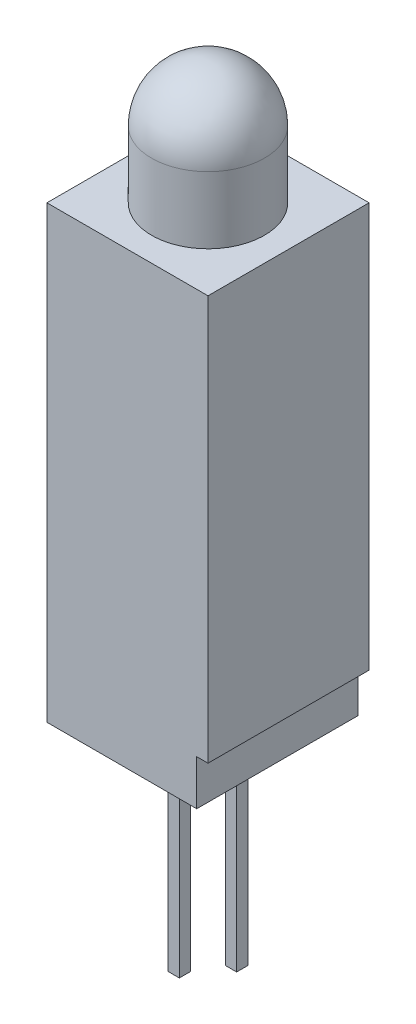
from build123d import *

# Parameters (mm, degrees)
EXTRUDE1_DEPTH     = 3.57
SKETCH1_5_W        = 0.5
SKETCH1_5_H        = 10.2
SKETCH1_5_H_2      = 8.7
EXTRUDE2_DEPTH     = 0.25
SKETCH2_W          = 0.025316456
SKETCH2_H          = 0.026582278
CUT_EXTRUDE1_DEPTH = 0.01


with BuildPart() as part:
    # Sketch1 → Extrude1 (new body, symmetric)
    with BuildSketch(Plane.XY):
        Polygon((0, 0), (-3.57, 0), (-3.57, -19.94), (-1.52, -19.94), (-1.02, -19.94), (1.02, -19.94), (1.52, -19.94), (3.07, -19.94), (3.07, -17.94), (3.57, -17.94), (3.57, 0), (2.5, 0), align=None)
    extrude(amount=EXTRUDE1_DEPTH, both=True)

    # Sketch1_4 → Revolve1 (revolve)
    with BuildSketch(Plane.XY, mode=Mode.PRIVATE) as revolve1_sk:
        with BuildLine():
            Line((0, 5.46), (0, 0))
            Line((0, 0), (2.5, 0))
            Line((2.5, 0), (2.5, 2.96))
            ThreePointArc((2.5, 2.96), (1.767766953, 4.727766953), (0, 5.46))
        make_face()
    revolve(revolve1_sk.sketch.rotate(Axis((0, 0, 0), (0, 1, 0)), 180), axis=Axis((0, 0, 0), (0, 1, 0)))  # turned: the seam where the file's is

    # Sketch1_5 → Extrude2 (add, symmetric)
    with BuildSketch(Plane.XY):
        with Locations((-1.27, -25.04)):
            Rectangle(SKETCH1_5_W, SKETCH1_5_H)
        with Locations((1.27, -24.29)):
            Rectangle(SKETCH1_5_W, SKETCH1_5_H_2)
    extrude(amount=EXTRUDE2_DEPTH, both=True)

    # Sketch2 → Cut-Extrude1 (cut)
    with BuildSketch(Plane.XZ.offset(19.94)):
        Polygon((-0.822151899, -2.5058483), (-0.845609177, -2.580531844), (-0.870352057, -2.580531844), (-0.886768196, -2.53019561), (-0.902294304, -2.580531844), (-0.928026108, -2.580531844), (-0.951265823, -2.5058483), (-0.926087816, -2.5058483), (-0.913093354, -2.557331686), (-0.896677215, -2.5058483), (-0.875178006, -2.5058483), (-0.858860759, -2.557331686), (-0.846044304, -2.5058483), align=None)
        Polygon((-0.687974684, -2.5058483), (-0.711431962, -2.580531844), (-0.736174842, -2.580531844), (-0.752590981, -2.53019561), (-0.768117089, -2.580531844), (-0.793848892, -2.580531844), (-0.817088608, -2.5058483), (-0.791910601, -2.5058483), (-0.778916139, -2.557331686), (-0.7625, -2.5058483), (-0.741000791, -2.5058483), (-0.724683544, -2.557331686), (-0.711867089, -2.5058483), align=None)
        Polygon((-0.553797468, -2.5058483), (-0.577254747, -2.580531844), (-0.601997627, -2.580531844), (-0.618413766, -2.53019561), (-0.633939873, -2.580531844), (-0.659671677, -2.580531844), (-0.682911392, -2.5058483), (-0.657733386, -2.5058483), (-0.644738924, -2.557331686), (-0.628322785, -2.5058483), (-0.606823576, -2.5058483), (-0.590506329, -2.557331686), (-0.577689873, -2.5058483), align=None)
        with Locations((-0.525949367, -2.567240705)):
            Rectangle(SKETCH2_W, SKETCH2_H)
        with BuildLine():
            add(Edge.make_bspline(
                [(-0.409493671, -2.549360958), (-0.40953016, -2.5505831), (-0.409601812, -2.552982978), (-0.41021153, -2.556490556), (-0.411205016, -2.559815261), (-0.412579134, -2.562977922), (-0.414367936, -2.56595654), (-0.416577526, -2.568736817), (-0.419141939, -2.571371618), (-0.422108149, -2.573777748), (-0.425388259, -2.575982124), (-0.428985835, -2.577879123), (-0.432864539, -2.579475606), (-0.437013125, -2.580814158), (-0.441459564, -2.581802738), (-0.446177094, -2.582526684), (-0.451170512, -2.583000013), (-0.45459409, -2.58304198), (-0.456348892, -2.58306349)],
                knots=[0, 0, 0, 0, 0.907352243, 1.781736951, 2.63548328, 3.47985091, 4.336556021, 5.208523475, 6.112432747, 7.062451073, 8.040435374, 9.043840564, 10.077958095, 11.152835584, 12.277940427, 13.457536469, 14.696825396, 16, 16, 16, 16], degree=3))
            add(Edge.make_bspline(
                [(-0.456348892, -2.58306349), (-0.458367148, -2.583039418), (-0.46227633, -2.582992794), (-0.467939855, -2.582564195), (-0.473207892, -2.581918055), (-0.478103607, -2.580951513), (-0.482708206, -2.579750748), (-0.487141474, -2.578459457), (-0.491422786, -2.576995041), (-0.494195876, -2.575894883), (-0.49556962, -2.575349882)],
                knots=[0, 0, 0, 0, 1.203215828, 2.33052265, 3.384689099, 4.366106119, 5.303329643, 6.221311756, 7.118865988, 8, 8, 8, 8], degree=3))
            Line((-0.49556962, -2.575349882), (-0.49556962, -2.55141792))
            Line((-0.49556962, -2.55141792), (-0.492721519, -2.55141792))
            add(Edge.make_bspline(
                [(-0.492721519, -2.55141792), (-0.491356205, -2.552499375), (-0.488633592, -2.554655936), (-0.484200359, -2.557418541), (-0.479552713, -2.559820704), (-0.474707243, -2.561794706), (-0.469810398, -2.56338103), (-0.46493502, -2.564474558), (-0.460169433, -2.565221907), (-0.457010864, -2.565302413), (-0.455458861, -2.565341971)],
                knots=[0, 0, 0, 0, 1.030622468, 2.055194264, 3.087043286, 4.125157485, 5.149848264, 6.130935704, 7.081611712, 8, 8, 8, 8], degree=3))
            add(Edge.make_bspline(
                [(-0.455458861, -2.565341971), (-0.455030085, -2.565341048), (-0.454112108, -2.56533907), (-0.452650581, -2.565211343), (-0.45099877, -2.565115766), (-0.449226261, -2.564908582), (-0.447429535, -2.564686722), (-0.445767134, -2.564311796), (-0.444257539, -2.563946929), (-0.443351018, -2.563578932), (-0.442919304, -2.56340368)],
                knots=[0, 0, 0, 0, 0.806402781, 1.726445712, 2.758724871, 3.919014682, 5.083870887, 6.16165551, 7.124521387, 8, 8, 8, 8], degree=3))
            add(Edge.make_bspline(
                [(-0.442919304, -2.56340368), (-0.442439741, -2.563175538), (-0.441497298, -2.562727191), (-0.440203698, -2.561916872), (-0.439036018, -2.561033407), (-0.437978647, -2.560068477), (-0.437104366, -2.558902726), (-0.436480499, -2.557494054), (-0.436135606, -2.555845036), (-0.436096583, -2.554669833), (-0.436075949, -2.554048458)],
                knots=[0, 0, 0, 0, 1.024747072, 2.013846092, 2.940605744, 3.850156746, 4.769278501, 5.73222711, 6.800942666, 8, 8, 8, 8], degree=3))
            add(Edge.make_bspline(
                [(-0.436075949, -2.554048458), (-0.436107794, -2.553502821), (-0.43617041, -2.552429937), (-0.436747603, -2.550894823), (-0.437657041, -2.549485655), (-0.438938631, -2.54821688), (-0.440531807, -2.547067346), (-0.442474191, -2.546085041), (-0.444724312, -2.545211853), (-0.446368382, -2.544793876), (-0.447231013, -2.544574566)],
                knots=[0, 0, 0, 0, 0.82557554, 1.623324704, 2.456147571, 3.35491006, 4.343819762, 5.427079081, 6.650009487, 8, 8, 8, 8], degree=3))
            add(Edge.make_bspline(
                [(-0.447231013, -2.544574566), (-0.449199639, -2.544126326), (-0.453238649, -2.543206675), (-0.459388473, -2.542067921), (-0.465516824, -2.540793061), (-0.469469591, -2.539586418), (-0.471400316, -2.538997034)],
                knots=[0, 0, 0, 0, 0.976100998, 2.002656142, 3.024398856, 4, 4, 4, 4], degree=3))
            add(Edge.make_bspline(
                [(-0.471400316, -2.538997034), (-0.472438835, -2.538644044), (-0.474460408, -2.537956916), (-0.477351919, -2.536795256), (-0.480013147, -2.535525427), (-0.48245286, -2.534169872), (-0.484653549, -2.532697332), (-0.486647817, -2.531155954), (-0.488410933, -2.529515914), (-0.489957738, -2.527776148), (-0.491282641, -2.525925445), (-0.492435025, -2.523980248), (-0.493417646, -2.521924828), (-0.494195684, -2.519754605), (-0.494820323, -2.51748095), (-0.495239305, -2.515103238), (-0.495538322, -2.512620109), (-0.495559046, -2.510925724), (-0.49556962, -2.510061117)],
                knots=[0, 0, 0, 0, 1.287047841, 2.5053592, 3.654260482, 4.74538952, 5.777514103, 6.75871007, 7.700244599, 8.599107454, 9.48590269, 10.366941872, 11.24940663, 12.154970331, 13.068988358, 14.012872203, 14.986013017, 16, 16, 16, 16], degree=3))
            add(Edge.make_bspline(
                [(-0.49556962, -2.510061117), (-0.495532318, -2.508904972), (-0.495458909, -2.5066297), (-0.49485748, -2.503300655), (-0.49383089, -2.500151919), (-0.492444827, -2.497148456), (-0.490616199, -2.49433537), (-0.488431404, -2.491656822), (-0.485807357, -2.489185231), (-0.482830235, -2.486884897), (-0.479542851, -2.484805499), (-0.476003867, -2.482974942), (-0.472234578, -2.481438291), (-0.468249032, -2.480164397), (-0.464030563, -2.479209726), (-0.45959333, -2.478490794), (-0.454919541, -2.478077612), (-0.45172812, -2.478026362), (-0.450098892, -2.478000199)],
                knots=[0, 0, 0, 0, 0.894990994, 1.761326291, 2.609044902, 3.454222546, 4.315366365, 5.200560057, 6.125081389, 7.100429509, 8.110379559, 9.133447974, 10.182136699, 11.259192205, 12.370181258, 13.528580438, 14.738335141, 16, 16, 16, 16], degree=3))
            add(Edge.make_bspline(
                [(-0.450098892, -2.478000199), (-0.448430198, -2.478022352), (-0.44509564, -2.47806662), (-0.4401143, -2.478445177), (-0.435159872, -2.478997489), (-0.430297448, -2.479846729), (-0.425605285, -2.480814961), (-0.42118617, -2.481914234), (-0.417106618, -2.48315174), (-0.414532965, -2.484106142), (-0.413291139, -2.484566655)],
                knots=[0, 0, 0, 0, 1.065407564, 2.129008667, 3.188544425, 4.247469455, 5.279542408, 6.247502114, 7.154394069, 8, 8, 8, 8], degree=3))
            Line((-0.413291139, -2.484566655), (-0.413291139, -2.507114123))
            Line((-0.413291139, -2.507114123), (-0.416119462, -2.507114123))
            add(Edge.make_bspline(
                [(-0.416119462, -2.507114123), (-0.417192966, -2.506314835), (-0.419383743, -2.50468367), (-0.423033347, -2.502581934), (-0.427000967, -2.500641843), (-0.431282594, -2.498950186), (-0.435742374, -2.497492179), (-0.440325133, -2.496472621), (-0.444951348, -2.495830913), (-0.448053052, -2.495758125), (-0.44960443, -2.495721718)],
                knots=[0, 0, 0, 0, 0.892265782, 1.820912499, 2.804518821, 3.836954028, 4.889985052, 5.931488012, 6.965393252, 8, 8, 8, 8], degree=3))
            add(Edge.make_bspline(
                [(-0.44960443, -2.495721718), (-0.450700035, -2.49574362), (-0.452897679, -2.495787554), (-0.45616687, -2.49617244), (-0.459407348, -2.496811293), (-0.46144203, -2.497627345), (-0.462460443, -2.4980358)],
                knots=[0, 0, 0, 0, 0.999122297, 2.004111588, 3.001004448, 4, 4, 4, 4], degree=3))
            add(Edge.make_bspline(
                [(-0.462460443, -2.4980358), (-0.462894173, -2.498236979), (-0.463761342, -2.498639203), (-0.464968884, -2.499418828), (-0.466089856, -2.500335172), (-0.467085439, -2.501387929), (-0.467929873, -2.502556283), (-0.468548899, -2.503823865), (-0.468923392, -2.505187747), (-0.468965739, -2.506122846), (-0.468987342, -2.506599882)],
                knots=[0, 0, 0, 0, 1.004925302, 2.009180302, 3.014392739, 4.04465309, 5.049195417, 6.035570224, 6.99785458, 8, 8, 8, 8], degree=3))
            add(Edge.make_bspline(
                [(-0.468987342, -2.506599882), (-0.468952904, -2.507238048), (-0.468887095, -2.508457523), (-0.468280511, -2.510173319), (-0.467295678, -2.511651753), (-0.466135073, -2.512646673), (-0.465017943, -2.513344111), (-0.463982284, -2.513854622), (-0.462773057, -2.514337981), (-0.461401809, -2.514835449), (-0.459865482, -2.515326637), (-0.458156925, -2.515802183), (-0.456274208, -2.516251479), (-0.454958333, -2.51653767), (-0.454272152, -2.516686908)],
                knots=[0, 0, 0, 0, 1.173816843, 2.243057204, 3.312297565, 4.415174738, 5.03266065, 5.73970059, 6.541434878, 7.433956553, 8.430083051, 9.515931566, 10.70464786, 12, 12, 12, 12], degree=3))
            add(Edge.make_bspline(
                [(-0.454272152, -2.516686908), (-0.452439229, -2.517062352), (-0.448844263, -2.517798723), (-0.443445039, -2.518911089), (-0.437940051, -2.520176448), (-0.434268899, -2.521328444), (-0.432357595, -2.521928205)],
                knots=[0, 0, 0, 0, 0.995749986, 1.952994291, 2.934271555, 4, 4, 4, 4], degree=3))
            add(Edge.make_bspline(
                [(-0.432357595, -2.521928205), (-0.431411107, -2.522247564), (-0.429559623, -2.522872282), (-0.426918075, -2.523956966), (-0.424469022, -2.525139055), (-0.422190751, -2.526361541), (-0.42012867, -2.527724758), (-0.418235447, -2.529139405), (-0.416552428, -2.530667514), (-0.415054478, -2.532280372), (-0.413736077, -2.533990804), (-0.412601114, -2.535828907), (-0.411637968, -2.537783436), (-0.410829836, -2.539856508), (-0.41025182, -2.542063576), (-0.409817762, -2.544389876), (-0.40952694, -2.546835192), (-0.409504884, -2.548509638), (-0.409493671, -2.549360958)],
                knots=[0, 0, 0, 0, 1.237386967, 2.420528625, 3.534815053, 4.605870898, 5.620827102, 6.594482803, 7.531295079, 8.432978826, 9.318460435, 10.202471551, 11.10474705, 12.014900263, 12.954095338, 13.926516828, 14.945802342, 16, 16, 16, 16], degree=3))
        make_face()
        with BuildLine():
            Line((-0.317088608, -2.580531844), (-0.341139241, -2.580531844))
            Line((-0.341139241, -2.580531844), (-0.341139241, -2.572699566))
            add(Edge.make_bspline(
                [(-0.341139241, -2.572699566), (-0.342232496, -2.573508233), (-0.344340276, -2.575067332), (-0.347514015, -2.577146096), (-0.350542736, -2.578929258), (-0.353464337, -2.580471411), (-0.356479693, -2.581662258), (-0.359707195, -2.582484114), (-0.363209459, -2.582985234), (-0.365636434, -2.583036825), (-0.366890823, -2.58306349)],
                knots=[0, 0, 0, 0, 1.150906677, 2.218931226, 3.20955724, 4.125565256, 5.012676028, 5.946647191, 6.938718366, 8, 8, 8, 8], degree=3))
            add(Edge.make_bspline(
                [(-0.366890823, -2.58306349), (-0.367907168, -2.583040761), (-0.369886286, -2.582996501), (-0.372763616, -2.582651763), (-0.375470927, -2.582113617), (-0.377987077, -2.581307761), (-0.380352422, -2.580333644), (-0.382503941, -2.579074557), (-0.38449163, -2.57761522), (-0.386295007, -2.575938284), (-0.387885627, -2.574017322), (-0.389272677, -2.571894572), (-0.390448489, -2.569559933), (-0.391390127, -2.567008566), (-0.392145061, -2.564250122), (-0.392669038, -2.561270915), (-0.392989618, -2.558083776), (-0.393021559, -2.555888647), (-0.393037975, -2.554760484)],
                knots=[0, 0, 0, 0, 1.108935798, 2.159418225, 3.158520219, 4.116592843, 5.038730546, 5.944611115, 6.829677354, 7.725673622, 8.624842385, 9.544872214, 10.487719724, 11.471363217, 12.50822837, 13.604887271, 14.769056852, 16, 16, 16, 16], degree=3))
            Line((-0.393037975, -2.554760484), (-0.393037975, -2.5058483))
            Line((-0.393037975, -2.5058483), (-0.368987342, -2.5058483))
            Line((-0.368987342, -2.5058483), (-0.368987342, -2.543427414))
            add(Edge.make_bspline(
                [(-0.368987342, -2.543427414), (-0.368985706, -2.544343885), (-0.368982576, -2.546098101), (-0.368900237, -2.548603907), (-0.368779336, -2.55087208), (-0.368640631, -2.552914108), (-0.368387615, -2.554760859), (-0.368009906, -2.55642702), (-0.36753908, -2.557946622), (-0.367074761, -2.558853324), (-0.366851266, -2.559289756)],
                knots=[0, 0, 0, 0, 1.361401701, 2.605856924, 3.723918663, 4.735739235, 5.645738665, 6.489217889, 7.27279937, 8, 8, 8, 8], degree=3))
            add(Edge.make_bspline(
                [(-0.366851266, -2.559289756), (-0.366621226, -2.559688404), (-0.366168987, -2.560472111), (-0.365249176, -2.561479259), (-0.364173193, -2.562316165), (-0.362903555, -2.562988809), (-0.361410474, -2.563472513), (-0.359678473, -2.56381926), (-0.357692458, -2.564033083), (-0.356283538, -2.564061245), (-0.355537975, -2.564076148)],
                knots=[0, 0, 0, 0, 0.849057291, 1.669173542, 2.503217716, 3.359509317, 4.311793648, 5.394940091, 6.621469141, 8, 8, 8, 8], degree=3))
            add(Edge.make_bspline(
                [(-0.355537975, -2.564076148), (-0.35499671, -2.564058691), (-0.353883832, -2.564022797), (-0.352178621, -2.563792869), (-0.350389592, -2.563431213), (-0.347875395, -2.562772189), (-0.34469925, -2.561593011), (-0.342335111, -2.560234209), (-0.341139241, -2.559546876)],
                knots=[0, 0, 0, 0, 0.638164724, 1.312110757, 2.025558264, 2.789159289, 4.375836335, 6, 6, 6, 6], degree=3))
            Line((-0.341139241, -2.559546876), (-0.341139241, -2.5058483))
            Line((-0.341139241, -2.5058483), (-0.317088608, -2.5058483))
            Line((-0.317088608, -2.5058483), (-0.317088608, -2.580531844))
        make_face()
        with BuildLine():
            Line((-0.219620253, -2.580531844), (-0.243670886, -2.580531844))
            Line((-0.243670886, -2.580531844), (-0.243670886, -2.542952731))
            add(Edge.make_bspline(
                [(-0.243670886, -2.542952731), (-0.24369121, -2.541422257), (-0.243731745, -2.538369845), (-0.244065325, -2.534613069), (-0.244399034, -2.531765279), (-0.244775857, -2.529929212), (-0.245206044, -2.528380876), (-0.24561849, -2.527495138), (-0.245806962, -2.527090389)],
                knots=[0, 0, 0, 0, 1.709235885, 3.408940626, 4.211008593, 4.910095588, 5.501954032, 6, 6, 6, 6], degree=3))
            add(Edge.make_bspline(
                [(-0.245806962, -2.527090389), (-0.24605139, -2.526692266), (-0.246530627, -2.525911691), (-0.247468442, -2.524899669), (-0.248565091, -2.524063456), (-0.249843815, -2.523398506), (-0.251328468, -2.522912608), (-0.253041142, -2.522525949), (-0.255027113, -2.522357388), (-0.256434481, -2.522322479), (-0.257179589, -2.522303996)],
                knots=[0, 0, 0, 0, 0.860145871, 1.686437142, 2.528070002, 3.393017362, 4.331453407, 5.402595683, 6.624848233, 8, 8, 8, 8], degree=3))
            add(Edge.make_bspline(
                [(-0.257179589, -2.522303996), (-0.258311478, -2.522360577), (-0.260622712, -2.52247611), (-0.263484003, -2.523189702), (-0.265810878, -2.524001999), (-0.267656499, -2.524776236), (-0.269573028, -2.525730861), (-0.270856452, -2.526457935), (-0.271518987, -2.526833269)],
                knots=[0, 0, 0, 0, 1.338419466, 2.732951426, 3.468143565, 4.254837763, 5.099104234, 6, 6, 6, 6], degree=3))
            Line((-0.271518987, -2.526833269), (-0.271518987, -2.580531844))
            Line((-0.271518987, -2.580531844), (-0.29556962, -2.580531844))
            Line((-0.29556962, -2.580531844), (-0.29556962, -2.5058483))
            Line((-0.29556962, -2.5058483), (-0.271518987, -2.5058483))
            Line((-0.271518987, -2.5058483), (-0.271518987, -2.513680579))
            add(Edge.make_bspline(
                [(-0.271518987, -2.513680579), (-0.27046175, -2.512874141), (-0.268403774, -2.511304362), (-0.265227022, -2.509270952), (-0.26215631, -2.507461096), (-0.259101788, -2.505948961), (-0.255977291, -2.504750361), (-0.25270966, -2.503934758), (-0.249292947, -2.50339181), (-0.246956274, -2.503341998), (-0.245767405, -2.503316655)],
                knots=[0, 0, 0, 0, 1.126064518, 2.191951536, 3.19307265, 4.144813015, 5.076393104, 6.021983703, 6.993610568, 8, 8, 8, 8], degree=3))
            add(Edge.make_bspline(
                [(-0.245767405, -2.503316655), (-0.244771134, -2.503342044), (-0.242826235, -2.503391608), (-0.239991474, -2.503701317), (-0.237320053, -2.504251981), (-0.234827778, -2.505049811), (-0.232485162, -2.506035424), (-0.230323205, -2.507266934), (-0.228331179, -2.508725374), (-0.22650261, -2.510386315), (-0.224872429, -2.512276273), (-0.223452943, -2.514392646), (-0.22228152, -2.516741375), (-0.221272688, -2.519288511), (-0.220538463, -2.522066282), (-0.220012012, -2.525057048), (-0.219661582, -2.52826223), (-0.219634305, -2.53047813), (-0.219620253, -2.531619661)],
                knots=[0, 0, 0, 0, 1.088441561, 2.124831547, 3.110816719, 4.062969431, 4.979391633, 5.88258537, 6.774334107, 7.671621258, 8.575503974, 9.49441354, 10.447872957, 11.437639084, 12.482478955, 13.580222388, 14.753440527, 16, 16, 16, 16], degree=3))
            Line((-0.219620253, -2.531619661), (-0.219620253, -2.580531844))
        make_face()
        Polygon((-0.124683544, -2.580531844), (-0.196835443, -2.580531844), (-0.196835443, -2.480531844), (-0.171518987, -2.480531844), (-0.171518987, -2.561544503), (-0.124683544, -2.561544503), align=None)
        Polygon((-0.037341772, -2.580531844), (-0.109493671, -2.580531844), (-0.109493671, -2.480531844), (-0.037341772, -2.480531844), (-0.037341772, -2.499519186), (-0.084177215, -2.499519186), (-0.084177215, -2.517240705), (-0.041139241, -2.517240705), (-0.041139241, -2.536228047), (-0.084177215, -2.536228047), (-0.084177215, -2.561544503), (-0.037341772, -2.561544503), align=None)
        with BuildLine():
            add(Edge.make_bspline(
                [(0.079113924, -2.530630737), (0.079094609, -2.531778426), (0.079056357, -2.534051312), (0.078761165, -2.537416118), (0.07823514, -2.540681794), (0.077555959, -2.543866042), (0.076633453, -2.54694497), (0.075551739, -2.549952547), (0.074242093, -2.552858041), (0.072737241, -2.555659475), (0.071087768, -2.558331578), (0.069313019, -2.560851787), (0.06746724, -2.563235005), (0.065477927, -2.565429899), (0.063398746, -2.567471918), (0.061223217, -2.569362732), (0.058918153, -2.571066163), (0.05731099, -2.572089048), (0.05650712, -2.572600674)],
                knots=[0, 0, 0, 0, 1.105570398, 2.18947457, 3.250358341, 4.290584537, 5.323553275, 6.344225964, 7.367641686, 8.3905646, 9.405808457, 10.390761353, 11.358902336, 12.307789878, 13.241960776, 14.165076779, 15.082208636, 16, 16, 16, 16], degree=3))
            add(Edge.make_bspline(
                [(0.05650712, -2.572600674), (0.055267899, -2.573312843), (0.052783134, -2.574740817), (0.048799188, -2.576408948), (0.044668069, -2.577816904), (0.040309515, -2.578865094), (0.035663167, -2.579593827), (0.03066851, -2.580156877), (0.025267382, -2.580457242), (0.0215325, -2.58050641), (0.019600475, -2.580531844)],
                knots=[0, 0, 0, 0, 0.896298978, 1.797171328, 2.70531317, 3.633678302, 4.606491125, 5.655688921, 6.787306437, 8, 8, 8, 8], degree=3))
            Line((0.019600475, -2.580531844), (-0.015822785, -2.580531844))
            Line((-0.015822785, -2.580531844), (-0.015822785, -2.480531844))
            Line((-0.015822785, -2.480531844), (0.020609177, -2.480531844))
            add(Edge.make_bspline(
                [(0.020609177, -2.480531844), (0.022587901, -2.48054854), (0.026404614, -2.480580743), (0.031915032, -2.480996712), (0.037013411, -2.481596231), (0.041697991, -2.482522923), (0.046006397, -2.483631575), (0.049937419, -2.48499461), (0.053549308, -2.486492882), (0.055728136, -2.48776663), (0.056784019, -2.488383901)],
                knots=[0, 0, 0, 0, 1.267192274, 2.444256634, 3.537982003, 4.553396635, 5.500903572, 6.385021601, 7.217363933, 8, 8, 8, 8], degree=3))
            add(Edge.make_bspline(
                [(0.056784019, -2.488383901), (0.057634972, -2.488920442), (0.059327097, -2.489987356), (0.061728312, -2.491769208), (0.063957739, -2.493725285), (0.066086242, -2.495777103), (0.068066056, -2.497979991), (0.069909269, -2.500318695), (0.071613036, -2.502796802), (0.073171192, -2.505406221), (0.074591277, -2.508136461), (0.075783356, -2.511008807), (0.076822718, -2.51399168), (0.077668801, -2.517090619), (0.07832513, -2.520308009), (0.078771214, -2.523645489), (0.079054647, -2.527098678), (0.079093999, -2.529443471), (0.079113924, -2.530630737)],
                knots=[0, 0, 0, 0, 0.964043478, 1.917004671, 2.862223898, 3.805158963, 4.749279098, 5.698713747, 6.657523689, 7.629652222, 8.610369353, 9.604453025, 10.607693792, 11.636365947, 12.681120053, 13.752669011, 14.862083412, 16, 16, 16, 16], degree=3))
        make_face()
        with BuildLine():
            add(Edge.make_bspline(
                [(0.052531646, -2.530472509), (0.052521175, -2.529667796), (0.052500636, -2.528089304), (0.052312313, -2.525773128), (0.052041725, -2.523547079), (0.051652591, -2.521403446), (0.051112159, -2.519353298), (0.050479977, -2.517391729), (0.049752887, -2.515512806), (0.048871957, -2.513735146), (0.047898133, -2.512026809), (0.046750689, -2.510441282), (0.045502338, -2.508928399), (0.044124055, -2.507500413), (0.042581114, -2.506194517), (0.040921012, -2.504964441), (0.039120654, -2.503836115), (0.037847665, -2.503176065), (0.037203323, -2.502841971)],
                knots=[0, 0, 0, 0, 1.152052275, 2.259818351, 3.325348653, 4.362224493, 5.376551665, 6.358740615, 7.312387502, 8.258104984, 9.197203025, 10.124507262, 11.056413058, 12.004389423, 12.961766972, 13.947352551, 14.961020569, 16, 16, 16, 16], degree=3))
            add(Edge.make_bspline(
                [(0.037203323, -2.502841971), (0.036528425, -2.502535259), (0.035190731, -2.501927334), (0.033119908, -2.501196142), (0.031030524, -2.500623306), (0.028828925, -2.500192448), (0.026359165, -2.499870517), (0.023433583, -2.499673259), (0.019977674, -2.49953109), (0.017490959, -2.499523338), (0.016159019, -2.499519186)],
                knots=[0, 0, 0, 0, 0.826967603, 1.639107464, 2.447640171, 3.242670507, 4.14065217, 5.225198036, 6.513753944, 8, 8, 8, 8], degree=3))
            Line((0.016159019, -2.499519186), (0.009493671, -2.499519186))
            Line((0.009493671, -2.499519186), (0.009493671, -2.561544503))
            Line((0.009493671, -2.561544503), (0.016159019, -2.561544503))
            add(Edge.make_bspline(
                [(0.016159019, -2.561544503), (0.016917226, -2.561539757), (0.018380993, -2.561530595), (0.02049723, -2.561487481), (0.022463046, -2.561440767), (0.024267852, -2.56132373), (0.025920195, -2.56125323), (0.027406342, -2.561069559), (0.028743292, -2.560935084), (0.030315773, -2.560657362), (0.03217096, -2.560251387), (0.034337749, -2.559568229), (0.036478448, -2.558718655), (0.037866999, -2.558033576), (0.038568038, -2.557687699)],
                knots=[0, 0, 0, 0, 1.186805873, 2.291202465, 3.313317863, 4.264127762, 5.122212376, 5.900577546, 6.607154111, 7.224697658, 8.398873738, 9.57716935, 10.776782771, 12, 12, 12, 12], degree=3))
            add(Edge.make_bspline(
                [(0.038568038, -2.557687699), (0.039153152, -2.557346181), (0.040307072, -2.556672663), (0.041930612, -2.555538613), (0.043438202, -2.554330803), (0.044834679, -2.553042662), (0.046096265, -2.551653277), (0.047252353, -2.550193811), (0.04825774, -2.54863349), (0.049496994, -2.546444663), (0.050744084, -2.543419906), (0.051776483, -2.539447152), (0.052415631, -2.535088241), (0.052491983, -2.5320505), (0.052531646, -2.530472509)],
                knots=[0, 0, 0, 0, 0.755237594, 1.489427721, 2.205882609, 2.908165467, 3.605466573, 4.296695275, 4.981837198, 5.673065901, 7.099889822, 8.61390339, 10.241051878, 12, 12, 12, 12], degree=3))
        make_face(mode=Mode.SUBTRACT)
        with Locations((0.110759494, -2.567240705)):
            Rectangle(SKETCH2_W, SKETCH2_H)
        with BuildLine():
            add(Edge.make_bspline(
                [(0.185403481, -2.58306349), (0.183813364, -2.583041687), (0.18069222, -2.582998891), (0.176120933, -2.582521862), (0.171755567, -2.581804566), (0.167609943, -2.580782247), (0.1636994, -2.579441728), (0.16004445, -2.577771721), (0.156627778, -2.575804526), (0.154565858, -2.574219629), (0.153540348, -2.57343137)],
                knots=[0, 0, 0, 0, 1.123701398, 2.205645569, 3.245398653, 4.249180969, 5.220497262, 6.163202923, 7.086456062, 8, 8, 8, 8], degree=3))
            add(Edge.make_bspline(
                [(0.153540348, -2.57343137), (0.152588713, -2.572576537), (0.150689124, -2.570870177), (0.148221497, -2.567899633), (0.146103421, -2.56461066), (0.144291165, -2.561019007), (0.142859214, -2.557099122), (0.141866679, -2.552849227), (0.141239075, -2.548291898), (0.141173123, -2.545143693), (0.141139241, -2.543526307)],
                knots=[0, 0, 0, 0, 0.916342154, 1.829140869, 2.758848968, 3.716597128, 4.708179637, 5.743612459, 6.840783343, 8, 8, 8, 8], degree=3))
            add(Edge.make_bspline(
                [(0.141139241, -2.543526307), (0.141178001, -2.541823079), (0.141253124, -2.538521999), (0.141916883, -2.533749812), (0.142986496, -2.529332131), (0.144524054, -2.525280223), (0.146454496, -2.521587031), (0.148718989, -2.518215197), (0.151339514, -2.515172272), (0.153346653, -2.513426833), (0.154351266, -2.512553205)],
                knots=[0, 0, 0, 0, 1.171797512, 2.271099083, 3.308930235, 4.294129479, 5.24602549, 6.17106565, 7.084581485, 8, 8, 8, 8], degree=3))
            add(Edge.make_bspline(
                [(0.154351266, -2.512553205), (0.15537705, -2.511784426), (0.157441008, -2.510237583), (0.160840547, -2.508342771), (0.16445276, -2.506738254), (0.168283877, -2.505492368), (0.172264395, -2.504543831), (0.176329936, -2.503816859), (0.180476303, -2.503396834), (0.183266488, -2.50334351), (0.184671677, -2.503316655)],
                knots=[0, 0, 0, 0, 0.952097844, 1.915695341, 2.885641886, 3.886921822, 4.905719434, 5.925883802, 6.95543633, 8, 8, 8, 8], degree=3))
            add(Edge.make_bspline(
                [(0.184671677, -2.503316655), (0.185918404, -2.503333618), (0.188369891, -2.503366975), (0.191970824, -2.503689632), (0.195419409, -2.504219797), (0.198716721, -2.504963391), (0.201889869, -2.505856189), (0.204949341, -2.50688747), (0.207914157, -2.508025411), (0.209814835, -2.508909626), (0.210759494, -2.509349091)],
                knots=[0, 0, 0, 0, 1.107671842, 2.178058178, 3.209662749, 4.206063564, 5.179815947, 6.137646632, 7.07438927, 8, 8, 8, 8], degree=3))
            Line((0.210759494, -2.509349091), (0.210759494, -2.529898933))
            Line((0.210759494, -2.529898933), (0.20741693, -2.529898933))
            add(Edge.make_bspline(
                [(0.20741693, -2.529898933), (0.206918162, -2.529480706), (0.205836226, -2.528573482), (0.204034874, -2.527172469), (0.201901363, -2.525621904), (0.200250156, -2.524735901), (0.199367089, -2.524262066)],
                knots=[0, 0, 0, 0, 0.792878214, 1.719922066, 2.780612869, 4, 4, 4, 4], degree=3))
            add(Edge.make_bspline(
                [(0.199367089, -2.524262066), (0.198439429, -2.523819198), (0.1965324, -2.522908774), (0.193972423, -2.522089231), (0.191783392, -2.521510694), (0.189971509, -2.521257884), (0.188038089, -2.521067536), (0.186702818, -2.521048141), (0.186016614, -2.521038174)],
                knots=[0, 0, 0, 0, 1.33256682, 2.739414054, 3.480190821, 4.267897792, 5.109861573, 6, 6, 6, 6], degree=3))
            add(Edge.make_bspline(
                [(0.186016614, -2.521038174), (0.185251065, -2.521057733), (0.183767468, -2.521095638), (0.181605865, -2.52137256), (0.179587789, -2.521851295), (0.177683381, -2.522489707), (0.175944635, -2.523385946), (0.174302105, -2.524398214), (0.172827629, -2.525652722), (0.171485682, -2.527070462), (0.170298198, -2.528660976), (0.169271446, -2.530387463), (0.168388719, -2.532245356), (0.167686826, -2.534243264), (0.167129316, -2.536373127), (0.166739751, -2.538635937), (0.166497972, -2.541035534), (0.166470029, -2.54268183), (0.166455696, -2.543526307)],
                knots=[0, 0, 0, 0, 1.087094245, 2.106738054, 3.087824582, 4.029427112, 4.95060567, 5.859714611, 6.763601524, 7.690850518, 8.627131371, 9.576106403, 10.539384251, 11.543302637, 12.578856349, 13.662518017, 14.800975475, 16, 16, 16, 16], degree=3))
            add(Edge.make_bspline(
                [(0.166455696, -2.543526307), (0.166470471, -2.544390463), (0.166499177, -2.546069475), (0.166732691, -2.548511086), (0.167148582, -2.550792518), (0.16771983, -2.552917838), (0.168444178, -2.554883856), (0.169349295, -2.556681252), (0.170385652, -2.55833806), (0.17163021, -2.559800672), (0.172994093, -2.561116993), (0.174508985, -2.562253128), (0.176168224, -2.563201273), (0.177950405, -2.564005736), (0.179883445, -2.564584134), (0.181939982, -2.565020826), (0.184129537, -2.565309382), (0.185639891, -2.565330945), (0.186412184, -2.565341971)],
                knots=[0, 0, 0, 0, 1.230336593, 2.390482092, 3.487897344, 4.52859895, 5.520747884, 6.465347575, 7.38981449, 8.296085817, 9.192433006, 10.084246191, 10.984321635, 11.908883871, 12.862027947, 13.850751296, 14.901019963, 16, 16, 16, 16], degree=3))
            add(Edge.make_bspline(
                [(0.186412184, -2.565341971), (0.187138026, -2.565333748), (0.188553028, -2.565317716), (0.190611451, -2.56510165), (0.192565368, -2.564822323), (0.194399915, -2.564381047), (0.196104164, -2.563846163), (0.197669817, -2.563275336), (0.199082423, -2.562671057), (0.199943758, -2.562203441), (0.200356013, -2.561979629)],
                knots=[0, 0, 0, 0, 1.200879421, 2.341068892, 3.423000803, 4.465923194, 5.460027553, 6.378409259, 7.223869634, 8, 8, 8, 8], degree=3))
            add(Edge.make_bspline(
                [(0.200356013, -2.561979629), (0.201064369, -2.561551943), (0.202425742, -2.560729984), (0.204250861, -2.559309524), (0.205894986, -2.557903084), (0.206919091, -2.556946317), (0.20741693, -2.556481212)],
                knots=[0, 0, 0, 0, 1.105932972, 2.12546697, 3.088749538, 4, 4, 4, 4], degree=3))
            Line((0.20741693, -2.556481212), (0.210759494, -2.556481212))
            Line((0.210759494, -2.556481212), (0.210759494, -2.577189281))
            add(Edge.make_bspline(
                [(0.210759494, -2.577189281), (0.209814117, -2.577626823), (0.207923136, -2.578502013), (0.205008359, -2.579655163), (0.202015116, -2.580628043), (0.198963886, -2.581520389), (0.195794254, -2.582218584), (0.192476905, -2.582707814), (0.188995601, -2.583009553), (0.186617185, -2.583045266), (0.185403481, -2.58306349)],
                knots=[0, 0, 0, 0, 0.952024047, 1.90427691, 2.862762905, 3.827874523, 4.80891974, 5.826446878, 6.890837857, 8, 8, 8, 8], degree=3))
        make_face()
        with BuildLine():
            add(Edge.make_bspline(
                [(0.303164557, -2.543229629), (0.303139637, -2.544734461), (0.303091062, -2.547667782), (0.302554854, -2.551940602), (0.301731391, -2.555971044), (0.300598066, -2.559771881), (0.299080213, -2.563314927), (0.297237799, -2.566610881), (0.295064208, -2.569663064), (0.292573889, -2.57245329), (0.289772404, -2.574951482), (0.286698638, -2.577147675), (0.283328772, -2.578954723), (0.279720026, -2.580481273), (0.275830719, -2.581637374), (0.271671624, -2.582455324), (0.267254115, -2.582989656), (0.264215749, -2.583038468), (0.262658228, -2.58306349)],
                knots=[0, 0, 0, 0, 1.120122129, 2.18341868, 3.201215738, 4.181270334, 5.131540819, 6.065757527, 6.988093576, 7.916512302, 8.844931028, 9.778115023, 10.722851943, 11.686686084, 12.691660064, 13.738321946, 14.84062285, 16, 16, 16, 16], degree=3))
            add(Edge.make_bspline(
                [(0.262658228, -2.58306349), (0.26110068, -2.58303855), (0.258062261, -2.582989899), (0.253645127, -2.582454428), (0.249490907, -2.581641711), (0.245606256, -2.580472476), (0.241991945, -2.578960385), (0.238618118, -2.577146944), (0.235543936, -2.574951691), (0.232742733, -2.57245318), (0.230251696, -2.569663295), (0.228080692, -2.566610066), (0.226229753, -2.563320273), (0.22474936, -2.559762999), (0.223576829, -2.55597579), (0.222764049, -2.551939792), (0.222224732, -2.547668001), (0.222176594, -2.544734535), (0.222151899, -2.543229629)],
                knots=[0, 0, 0, 0, 1.159424321, 2.261770074, 3.308474541, 4.308788811, 5.277191138, 6.221966496, 7.15518846, 8.08364496, 9.01210146, 9.934475036, 10.868729753, 11.817121636, 12.798654016, 13.816492484, 14.879832297, 16, 16, 16, 16], degree=3))
            add(Edge.make_bspline(
                [(0.222151899, -2.543229629), (0.222177022, -2.541718206), (0.222226107, -2.538765195), (0.222761477, -2.534466322), (0.223579494, -2.530405672), (0.224739526, -2.526597359), (0.226255799, -2.523045759), (0.228096824, -2.519743654), (0.230293292, -2.516697079), (0.23280279, -2.513907328), (0.235614584, -2.511410947), (0.238708516, -2.509238041), (0.242060435, -2.507401384), (0.245667634, -2.505879551), (0.24955419, -2.504744985), (0.253691132, -2.503927407), (0.258088526, -2.503389334), (0.261107264, -2.503341322), (0.262658228, -2.503316655)],
                knots=[0, 0, 0, 0, 1.124034801, 2.196132384, 3.217834281, 4.203147447, 5.152578239, 6.085969439, 7.010345409, 7.941219594, 8.872481455, 9.802010446, 10.748267785, 11.711250247, 12.709230373, 13.754967386, 14.846549946, 16, 16, 16, 16], degree=3))
            add(Edge.make_bspline(
                [(0.262658228, -2.503316655), (0.264228972, -2.503341367), (0.267287148, -2.50338948), (0.271730477, -2.503925819), (0.275904607, -2.504738345), (0.279802216, -2.505906415), (0.283426224, -2.507409685), (0.2867734, -2.509264631), (0.289858359, -2.511438981), (0.292626621, -2.51396881), (0.29511038, -2.516763764), (0.297272736, -2.519821444), (0.299108213, -2.52312902), (0.300583955, -2.526690895), (0.301758158, -2.530483527), (0.302578569, -2.534517954), (0.303084721, -2.53879286), (0.303137483, -2.541725003), (0.303164557, -2.543229629)],
                knots=[0, 0, 0, 0, 1.167473013, 2.273023816, 3.322954552, 4.326451713, 5.293391623, 6.234801871, 7.166614545, 8.093305908, 9.017100806, 9.942078766, 10.872536262, 11.824015763, 12.804065898, 13.820367293, 14.881523901, 16, 16, 16, 16], degree=3))
        make_face()
        with BuildLine():
            add(Edge.make_bspline(
                [(0.273457278, -2.561722509), (0.273812024, -2.561222316), (0.274533974, -2.560204364), (0.275409914, -2.558509172), (0.276169567, -2.556677904), (0.276788254, -2.554651621), (0.277298396, -2.552353844), (0.277600016, -2.549696912), (0.277832831, -2.546662026), (0.277842811, -2.544509218), (0.277848101, -2.543368079)],
                knots=[0, 0, 0, 0, 0.765094823, 1.557058493, 2.376706509, 3.238810155, 4.199844458, 5.312104478, 6.575226644, 8, 8, 8, 8], degree=3))
            add(Edge.make_bspline(
                [(0.277848101, -2.543368079), (0.277830412, -2.542293197), (0.277796522, -2.540233841), (0.277610152, -2.537274078), (0.277261478, -2.534590652), (0.2767636, -2.532173255), (0.276153829, -2.530002567), (0.275427894, -2.528060205), (0.274589376, -2.526341603), (0.273903909, -2.525336371), (0.273575949, -2.52485542)],
                knots=[0, 0, 0, 0, 1.337076348, 2.561692668, 3.686680134, 4.69989255, 5.629188848, 6.488203485, 7.276684665, 8, 8, 8, 8], degree=3))
            add(Edge.make_bspline(
                [(0.273575949, -2.52485542), (0.273237376, -2.524417583), (0.272576126, -2.523562466), (0.271418372, -2.522458832), (0.270137891, -2.521580883), (0.268757044, -2.520912218), (0.267316335, -2.520398708), (0.265810213, -2.520042667), (0.264253653, -2.519821504), (0.263192974, -2.519788826), (0.262658228, -2.519772351)],
                knots=[0, 0, 0, 0, 1.058499091, 2.067300666, 3.047512573, 4.018335651, 4.996351322, 5.969796037, 6.97646375, 8, 8, 8, 8], degree=3))
            add(Edge.make_bspline(
                [(0.262658228, -2.519772351), (0.262130325, -2.519783381), (0.261097766, -2.519804955), (0.259594689, -2.519983472), (0.258179036, -2.52028347), (0.25683387, -2.520687656), (0.255548722, -2.521299032), (0.254317445, -2.52214785), (0.253102058, -2.52322443), (0.25236373, -2.524074765), (0.251977848, -2.524519186)],
                knots=[0, 0, 0, 0, 1.04189444, 2.037910168, 2.982338511, 3.896140384, 4.804271323, 5.778885192, 6.839150358, 8, 8, 8, 8], degree=3))
            add(Edge.make_bspline(
                [(0.251977848, -2.524519186), (0.251642414, -2.524992854), (0.250938424, -2.525986962), (0.250089235, -2.527707331), (0.249319936, -2.529652823), (0.248640648, -2.531843958), (0.248109463, -2.534311498), (0.247751274, -2.537070111), (0.247506594, -2.540120046), (0.247481478, -2.542253352), (0.247468354, -2.543368079)],
                knots=[0, 0, 0, 0, 0.70629823, 1.482341141, 2.329662943, 3.254583898, 4.274063958, 5.401087491, 6.641978366, 8, 8, 8, 8], degree=3))
            add(Edge.make_bspline(
                [(0.247468354, -2.543368079), (0.247474295, -2.544370818), (0.2474858, -2.546312949), (0.247727995, -2.549115281), (0.248014823, -2.551723725), (0.248501392, -2.554111778), (0.24907323, -2.556296955), (0.249821274, -2.558248548), (0.250644614, -2.560003621), (0.251344968, -2.561031361), (0.251681171, -2.561524724)],
                knots=[0, 0, 0, 0, 1.270983191, 2.461674417, 3.564986371, 4.596265355, 5.549463796, 6.425202083, 7.244022889, 8, 8, 8, 8], degree=3))
            add(Edge.make_bspline(
                [(0.251681171, -2.561524724), (0.252021533, -2.561941499), (0.252692579, -2.562763197), (0.253840375, -2.563839338), (0.255108347, -2.564713895), (0.256457966, -2.565436884), (0.257924557, -2.565971267), (0.259484843, -2.5663412), (0.261142292, -2.56656034), (0.262275179, -2.56659171), (0.262856013, -2.566607794)],
                knots=[0, 0, 0, 0, 1.010886179, 1.993025998, 2.945391046, 3.898964935, 4.863589088, 5.87059323, 6.908247091, 8, 8, 8, 8], degree=3))
            add(Edge.make_bspline(
                [(0.262856013, -2.566607794), (0.263863641, -2.566555272), (0.265861448, -2.566451139), (0.268276869, -2.565734733), (0.270078527, -2.564879754), (0.271333325, -2.564020345), (0.272471635, -2.562959577), (0.273124499, -2.562140175), (0.273457278, -2.561722509)],
                knots=[0, 0, 0, 0, 1.49343762, 2.961012893, 3.700518105, 4.446788108, 5.208294864, 6, 6, 6, 6], degree=3))
        make_face(mode=Mode.SUBTRACT)
        with BuildLine():
            Line((0.394303797, -2.526833269), (0.394303797, -2.580531844))
            Line((0.394303797, -2.580531844), (0.370253165, -2.580531844))
            Line((0.370253165, -2.580531844), (0.370253165, -2.542675832))
            add(Edge.make_bspline(
                [(0.370253165, -2.542675832), (0.370246898, -2.541785832), (0.370234875, -2.540078267), (0.370212363, -2.537617937), (0.370096991, -2.535370595), (0.370000439, -2.53332326), (0.369801755, -2.531466874), (0.369524083, -2.529787166), (0.369095228, -2.528284169), (0.368687802, -2.527383055), (0.36849288, -2.526951939)],
                knots=[0, 0, 0, 0, 1.33997484, 2.570892857, 3.703483919, 4.727540125, 5.655929516, 6.512630168, 7.288405602, 8, 8, 8, 8], degree=3))
            add(Edge.make_bspline(
                [(0.36849288, -2.526951939), (0.368282954, -2.526566572), (0.36786683, -2.525802679), (0.366998785, -2.524834818), (0.365990476, -2.524024173), (0.364810314, -2.523382719), (0.363431631, -2.522884556), (0.361816509, -2.522535211), (0.359952652, -2.522354809), (0.358630364, -2.522321571), (0.357931171, -2.522303996)],
                knots=[0, 0, 0, 0, 0.859345536, 1.703436662, 2.532498256, 3.390183975, 4.328249457, 5.402602062, 6.626559876, 8, 8, 8, 8], degree=3))
            add(Edge.make_bspline(
                [(0.357931171, -2.522303996), (0.357343832, -2.522327392), (0.356163857, -2.522374393), (0.354399742, -2.522619336), (0.352672133, -2.523114718), (0.350453045, -2.523952429), (0.347854183, -2.525176621), (0.345886252, -2.526294084), (0.344936709, -2.526833269)],
                knots=[0, 0, 0, 0, 0.759382397, 1.525614786, 2.294447385, 3.076151307, 4.589219126, 6, 6, 6, 6], degree=3))
            Line((0.344936709, -2.526833269), (0.344936709, -2.580531844))
            Line((0.344936709, -2.580531844), (0.320886076, -2.580531844))
            Line((0.320886076, -2.580531844), (0.320886076, -2.5058483))
            Line((0.320886076, -2.5058483), (0.344936709, -2.5058483))
            Line((0.344936709, -2.5058483), (0.344936709, -2.513680579))
            add(Edge.make_bspline(
                [(0.344936709, -2.513680579), (0.345957797, -2.512899199), (0.347940337, -2.511382076), (0.350953613, -2.509334747), (0.353906507, -2.507579163), (0.356799194, -2.506031268), (0.359752873, -2.504791653), (0.362851277, -2.503948713), (0.366094567, -2.503417641), (0.368312774, -2.503350726), (0.369442247, -2.503316655)],
                knots=[0, 0, 0, 0, 1.136109262, 2.205863928, 3.217041414, 4.170849475, 5.103496751, 6.040664374, 7.002340634, 8, 8, 8, 8], degree=3))
            add(Edge.make_bspline(
                [(0.369442247, -2.503316655), (0.370645481, -2.503348409), (0.37299712, -2.50341047), (0.376409162, -2.50407961), (0.379624607, -2.505084678), (0.382582226, -2.506573497), (0.385302424, -2.508414949), (0.387715584, -2.510671688), (0.389805479, -2.513338931), (0.39089703, -2.515344157), (0.391455696, -2.516370452)],
                knots=[0, 0, 0, 0, 1.065971563, 2.0833675, 3.072814207, 4.045738768, 5.009267307, 5.977487593, 6.964858173, 8, 8, 8, 8], degree=3))
            add(Edge.make_bspline(
                [(0.391455696, -2.516370452), (0.392637781, -2.515393487), (0.394941436, -2.513489572), (0.398495052, -2.510946949), (0.401974132, -2.508692392), (0.405414652, -2.506783567), (0.408815096, -2.505233013), (0.412197602, -2.504139026), (0.415544031, -2.503446662), (0.417771115, -2.503359574), (0.418868671, -2.503316655)],
                knots=[0, 0, 0, 0, 1.188147474, 2.315470194, 3.384102413, 4.399459064, 5.362307068, 6.27522031, 7.149990929, 8, 8, 8, 8], degree=3))
            add(Edge.make_bspline(
                [(0.418868671, -2.503316655), (0.419851921, -2.50334005), (0.421765063, -2.50338557), (0.42454762, -2.503720585), (0.427143805, -2.504292314), (0.429562078, -2.505081245), (0.431795216, -2.506113552), (0.433841647, -2.507389863), (0.435714647, -2.508875664), (0.437386566, -2.510597326), (0.438872492, -2.512521459), (0.440168729, -2.514656426), (0.441246883, -2.516996509), (0.442144985, -2.519531018), (0.442829098, -2.522267201), (0.443319166, -2.525210117), (0.443617377, -2.528350048), (0.443652749, -2.530511396), (0.443670886, -2.531619661)],
                knots=[0, 0, 0, 0, 1.099528869, 2.139389204, 3.128691273, 4.06836032, 4.978849901, 5.872980696, 6.759662307, 7.646067956, 8.55014577, 9.473266406, 10.433198647, 11.426668526, 12.476415665, 13.583140093, 14.760718182, 16, 16, 16, 16], degree=3))
            Line((0.443670886, -2.531619661), (0.443670886, -2.580531844))
            Line((0.443670886, -2.580531844), (0.419620253, -2.580531844))
            Line((0.419620253, -2.580531844), (0.419620253, -2.542675832))
            add(Edge.make_bspline(
                [(0.419620253, -2.542675832), (0.419614543, -2.541779215), (0.419603583, -2.54005842), (0.419573902, -2.537592067), (0.419484266, -2.53534425), (0.419403721, -2.533304358), (0.4192351, -2.531452225), (0.418948066, -2.529780575), (0.418517939, -2.528288587), (0.418126047, -2.527383663), (0.417939082, -2.526951939)],
                knots=[0, 0, 0, 0, 1.350843832, 2.592553583, 3.715618503, 4.739861077, 5.667890227, 6.515410335, 7.291728161, 8, 8, 8, 8], degree=3))
            add(Edge.make_bspline(
                [(0.417939082, -2.526951939), (0.417735705, -2.526566934), (0.417333047, -2.525804679), (0.416483935, -2.524829687), (0.415472098, -2.524019159), (0.414275171, -2.523383506), (0.412877515, -2.522884615), (0.411242699, -2.52253545), (0.409352701, -2.522354154), (0.408010647, -2.522321389), (0.407298259, -2.522303996)],
                knots=[0, 0, 0, 0, 0.84645005, 1.675850114, 2.498752818, 3.361341904, 4.304511378, 5.383432037, 6.611077598, 8, 8, 8, 8], degree=3))
            add(Edge.make_bspline(
                [(0.407298259, -2.522303996), (0.406297666, -2.522352446), (0.40427854, -2.522450213), (0.401790256, -2.523153184), (0.399774065, -2.523982826), (0.398078326, -2.524756056), (0.396237567, -2.525726478), (0.394967402, -2.526453455), (0.394303797, -2.526833269)],
                knots=[0, 0, 0, 0, 1.291070249, 2.605286939, 3.312383926, 4.109045945, 5.012060117, 6, 6, 6, 6], degree=3))
        make_face()
    extrude(amount=-CUT_EXTRUDE1_DEPTH, mode=Mode.SUBTRACT)


solid = part.part
